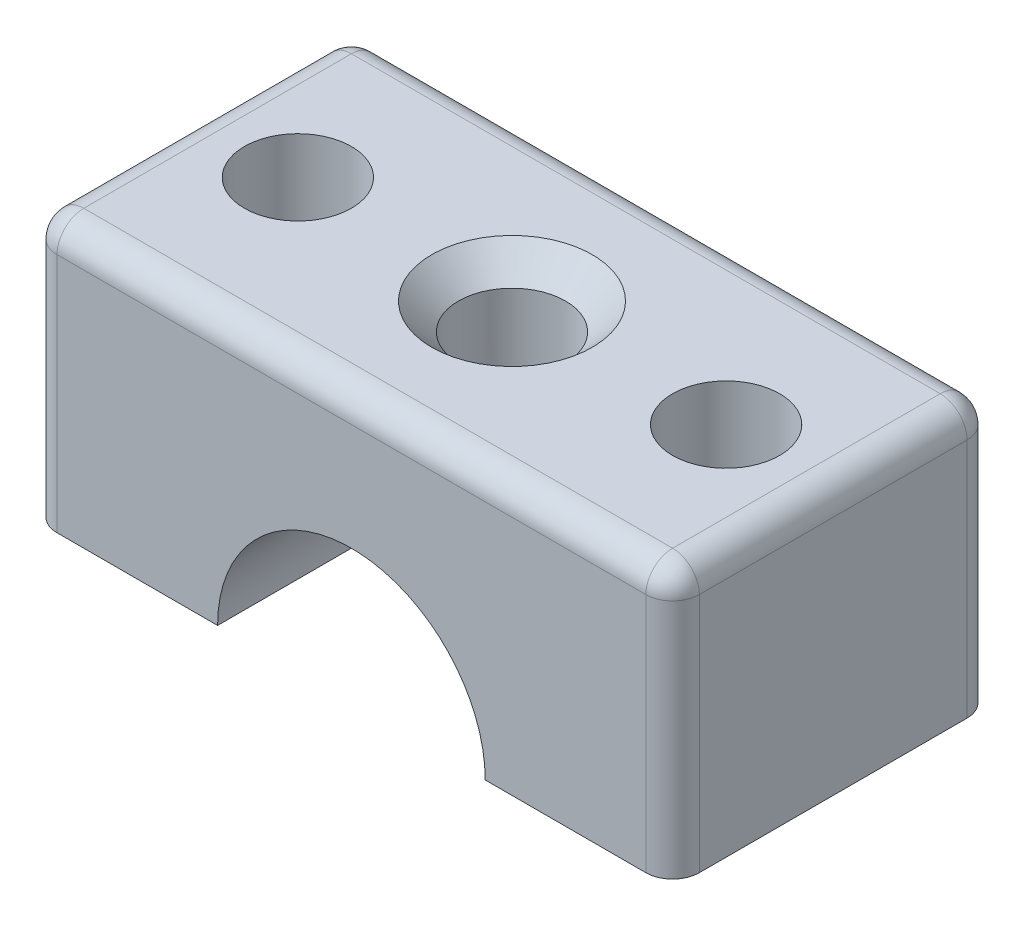
from build123d import *

# Parameters (mm, degrees)
SKETCH1_W           = 24
SKETCH1_H           = 12
SKETCH1_R           = 2
BOSS_EXTRUDE1_DEPTH = 10
CHAMFER1_SIZE       = 1
FILLET1_R           = 1
CUT_EXTRUDE1_DEPTH  = 13


with BuildPart() as part:
    # Sketch1 → Boss-Extrude1 (new body)
    with BuildSketch(Plane(origin=(0, 0, 0), x_dir=(1, 0, 0), z_dir=(0, 1, 0))):
        Rectangle(SKETCH1_W, SKETCH1_H)
        with Locations((8, 0)):
            Circle(SKETCH1_R, mode=Mode.SUBTRACT)
        with Locations((-8, 0)):
            Circle(SKETCH1_R, mode=Mode.SUBTRACT)
        Circle(SKETCH1_R, mode=Mode.SUBTRACT)
    extrude(amount=BOSS_EXTRUDE1_DEPTH)

    # Chamfer1
    chamfer1_edges = [part.edges().sort_by_distance(p)[0] for p in [
        (-2, 10, 0),
    ]]
    chamfer(chamfer1_edges, length=CHAMFER1_SIZE)

    # Fillet1
    fillet1_edges = [part.edges().sort_by_distance(p)[0] for p in [
        (-12, 10, 0),
        (0, 10, 6),
        (12, 10, 0),
        (12, 5, 6),
        (-12, 5, 6),
        (-12, 5, -6),
        (12, 5, -6),
        (0, 10, -6),
    ]]
    fillet(fillet1_edges, radius=FILLET1_R)

    # Sketch2 → Cut-Extrude1 (cut, through all)
    with BuildSketch(Plane(origin=(0, 0, -6), x_dir=(-1, 0, 0), z_dir=(0, 0, -1))):
        with BuildLine():
            Line((-5, 0), (5, 0))
            ThreePointArc((5, 0), (0, 5), (-5, 0))
        make_face()
    extrude(amount=-CUT_EXTRUDE1_DEPTH, mode=Mode.SUBTRACT)


solid = part.part
